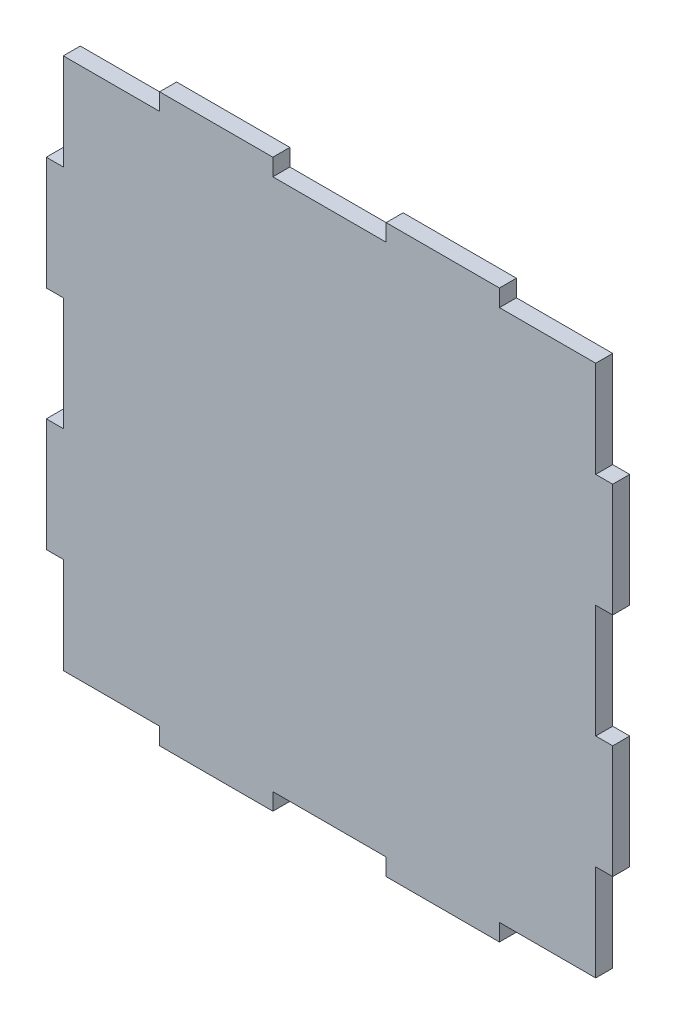
from build123d import *

# Parameters (mm, degrees)
EXTRUDE_1_DEPTH = 3


with BuildPart() as part:
    # 草图1 → 凸台-拉伸1 (new body)
    with BuildSketch(Plane.XY):
        Polygon((-10, 47), (10, 47), (10, 50), (30, 50), (30, 47), (47, 47), (47, 30), (50, 30), (50, 10), (47, 10), (47, -10), (50, -10), (50, -30), (47, -30), (47, -47), (30, -47), (30, -50), (10, -50), (10, -47), (-10, -47), (-10, -50), (-30, -50), (-30, -47), (-47, -47), (-47, -30), (-50, -30), (-50, -10), (-47, -10), (-47, 10), (-50, 10), (-50, 30), (-47, 30), (-47, 47), (-30, 47), (-30, 50), (-10, 50), align=None)
    extrude(amount=EXTRUDE_1_DEPTH)


solid = part.part
